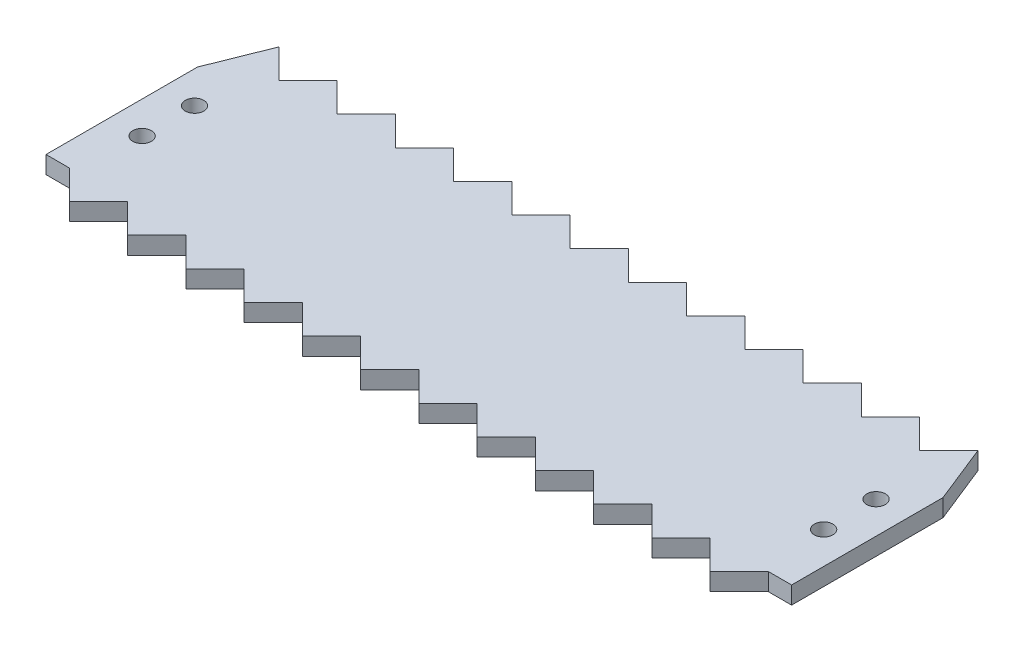
from build123d import *

# Parameters (mm, degrees)
SKETCH1_W               = 128
SKETCH1_H               = 41
BOSS_EXTRUDE1_DEPTH     = 3
CUT_EXTRUDE2_START      = -4
CUT_EXTRUDE2_DEPTH      = 5
LPATTERN3_COUNT         = 12
LPATTERN3_PITCH         = 10
CUT_EXTRUDE3_START      = -4
CUT_EXTRUDE3_DEPTH      = 5
LPATTERN5_COUNT         = 12
LPATTERN5_PITCH         = 10
CUT_EXTRUDE4_START      = -4
SKETCH6_R               = 1.6
CUT_EXTRUDE4_DEPTH      = 5
MIRROR3_START           = -4
MIRROR3_COPY_1_SKETCH_R = 1.6
MIRROR3_COPY_1_DEPTH    = 5
CUT_EXTRUDE5_START      = -4
CUT_EXTRUDE5_DEPTH      = 5
CUT_EXTRUDE6_START      = -4
SKETCH8_W               = 4
SKETCH8_H               = 5
CUT_EXTRUDE6_DEPTH      = 5


with BuildPart() as part:
    # Sketch1 → Boss-Extrude1 (new body)
    with BuildSketch(Plane(origin=(0, 0, 0), x_dir=(1, 0, 0), z_dir=(0, 1, 0))):
        Rectangle(SKETCH1_W, SKETCH1_H)
    extrude(amount=BOSS_EXTRUDE1_DEPTH)

    # Sketch2 → Cut-Extrude2 (cut)
    with BuildSketch(Plane(origin=(0, 3, 0), x_dir=(1, 0, 0), z_dir=(0, 1, 0)).offset(CUT_EXTRUDE2_START)):
        Polygon((-60, 20.5), (-55, 15.5), (-50, 20.5), align=None)
    cut_extrude2 = extrude(amount=CUT_EXTRUDE2_DEPTH, mode=Mode.SUBTRACT)

    # LPattern3: Cut-Extrude2 ×12
    with Locations(*[(i * LPATTERN3_PITCH, 0, 0) for i in range(1, LPATTERN3_COUNT)]):
        add(cut_extrude2, mode=Mode.SUBTRACT)

    # Sketch5 → Cut-Extrude3 (cut)
    with BuildSketch(Plane(origin=(0, 3, 0), x_dir=(1, 0, 0), z_dir=(0, 1, 0)).offset(CUT_EXTRUDE3_START)):
        Polygon((-55, -20.5), (-60, -15.5), (-60, -20.5), align=None)
        Polygon((-50, -15.5), (-55, -20.5), (-50, -20.5), align=None)
    cut_extrude3 = extrude(amount=CUT_EXTRUDE3_DEPTH, mode=Mode.SUBTRACT)

    # LPattern5: Cut-Extrude3 ×12
    with Locations(*[(i * LPATTERN5_PITCH, 0, 0) for i in range(1, LPATTERN5_COUNT)]):
        add(cut_extrude3, mode=Mode.SUBTRACT)

    # Sketch6 → Cut-Extrude4 (cut)
    with BuildSketch(Plane(origin=(0, 3, 0), x_dir=(1, 0, 0), z_dir=(0, 1, 0)).offset(CUT_EXTRUDE4_START)):
        with Locations((-58.5, 4.5)):
            Circle(SKETCH6_R)
    cut_extrude4 = extrude(amount=CUT_EXTRUDE4_DEPTH, mode=Mode.SUBTRACT)

    # Mirror2: Cut-Extrude4 across plane
    add(cut_extrude4.mirror(Plane(origin=(0, 0, 0), x_dir=(0, 0, 1), z_dir=(1, 0, 0))), mode=Mode.SUBTRACT)

    # Mirror3: Cut-Extrude4 across plane
    add(cut_extrude4.mirror(Plane.XY), mode=Mode.SUBTRACT)

    # Mirror3 copy 1 sketch → Mirror3 copy 1 (cut)
    with BuildSketch(Plane(origin=(0, 3, 0), x_dir=(-1, 0, 0), z_dir=(0, 1, 0)).offset(MIRROR3_START)):
        with Locations((-58.5, 4.5)):
            Circle(MIRROR3_COPY_1_SKETCH_R)
    extrude(amount=MIRROR3_COPY_1_DEPTH, mode=Mode.SUBTRACT)

    # Sketch7 → Cut-Extrude5 (cut)
    with BuildSketch(Plane(origin=(0, 3, 0), x_dir=(1, 0, 0), z_dir=(0, 1, 0)).offset(CUT_EXTRUDE5_START)):
        Polygon((-60, 20.5), (-64, 10.5), (-64, 20.5), align=None)
    cut_extrude5 = extrude(amount=CUT_EXTRUDE5_DEPTH, mode=Mode.SUBTRACT)

    # Mirror4: Cut-Extrude5 across plane
    add(cut_extrude5.mirror(Plane(origin=(0, 0, 0), x_dir=(0, 0, 1), z_dir=(1, 0, 0))), mode=Mode.SUBTRACT)

    # Sketch8 → Cut-Extrude6 (cut)
    with BuildSketch(Plane(origin=(0, 3, 0), x_dir=(1, 0, 0), z_dir=(0, 1, 0)).offset(CUT_EXTRUDE6_START)):
        with Locations((-62, -18)):
            Rectangle(SKETCH8_W, SKETCH8_H)
    cut_extrude6 = extrude(amount=CUT_EXTRUDE6_DEPTH, mode=Mode.SUBTRACT)

    # Mirror5: Cut-Extrude6 across plane
    add(cut_extrude6.mirror(Plane(origin=(0, 0, 0), x_dir=(0, 0, 1), z_dir=(1, 0, 0))), mode=Mode.SUBTRACT)


solid = part.part
